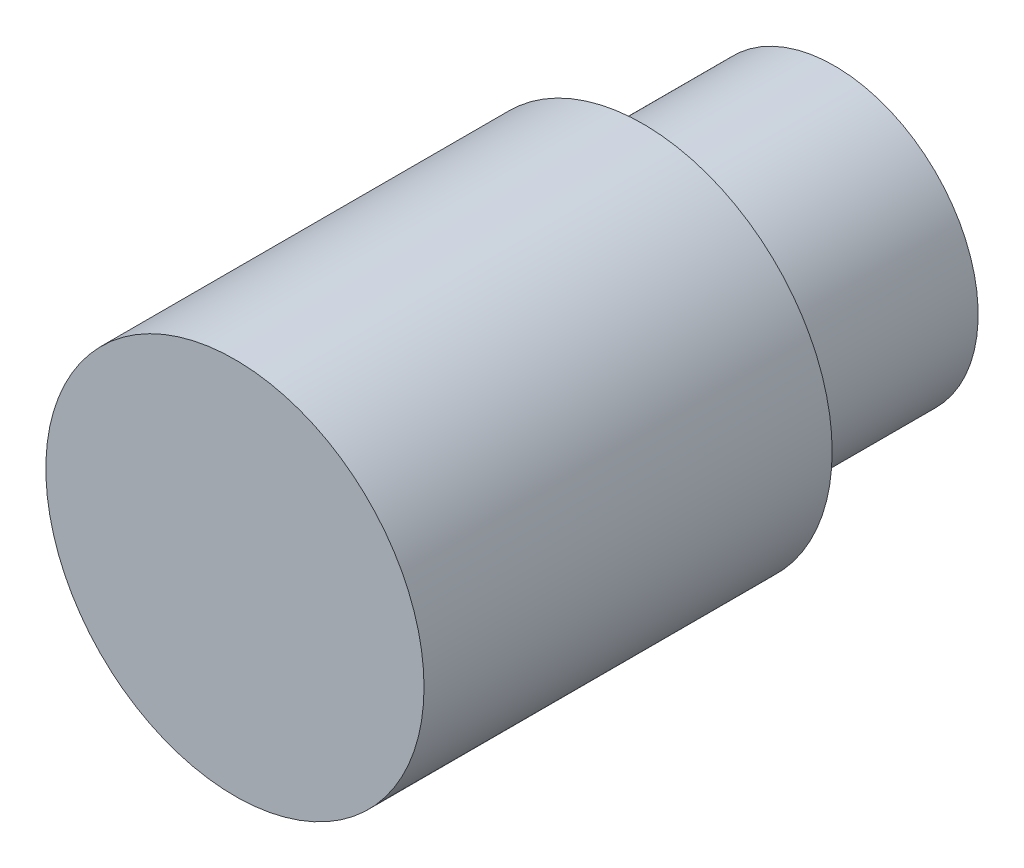
from build123d import *

# Parameters (mm, degrees)
SKETCH_1_R      = 7.9
EXTRUDE_1_DEPTH = 17.05
SKETCH_2_R      = 6
EXTRUDE_2_DEPTH = 8


with BuildPart() as part:
    # Эскиз1 → Бобышка-Вытянуть1 (new body)
    with BuildSketch(Plane.XY):
        Circle(SKETCH_1_R)
    extrude(amount=-EXTRUDE_1_DEPTH)

    # Эскиз2 → Бобышка-Вытянуть2 (add)
    with BuildSketch(Plane(origin=(0, 0, -17.05), x_dir=(-1, 0, 0), z_dir=(0, 0, -1))):
        with Locations((-0.000152147, 0.000225784)):
            Circle(SKETCH_2_R)
    extrude(amount=EXTRUDE_2_DEPTH)


solid = part.part
